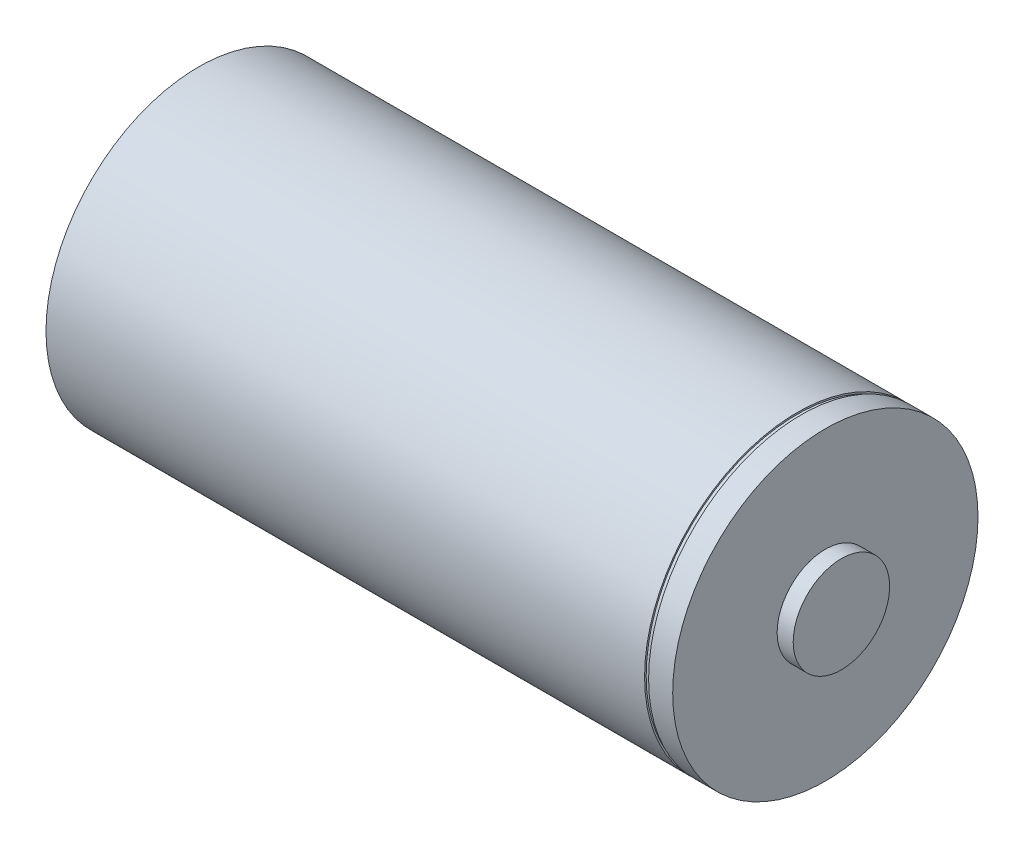
from build123d import *

# Parameters (mm, degrees)
SKIZZE2_W = 0.5
SKIZZE2_H = 0.2


with BuildPart() as part:
    # Skizze1 → Rotation1 (revolve)
    with BuildSketch(Plane.XY):
        Polygon((0, 0), (0, 19), (78, 19), (78, 6), (80, 6), (80, 0), align=None)
    revolve(axis=Axis((0, 0, 0), (1, 0, 0)))

    # Skizze2 → Schnitt-Rotation1 (revolve, cut)
    with BuildSketch(Plane.XY):
        with Locations((74.75, 18.9)):
            Rectangle(SKIZZE2_W, SKIZZE2_H)
    revolve(axis=Axis((0, 0, 0), (1, 0, 0)), mode=Mode.SUBTRACT)


solid = part.part
